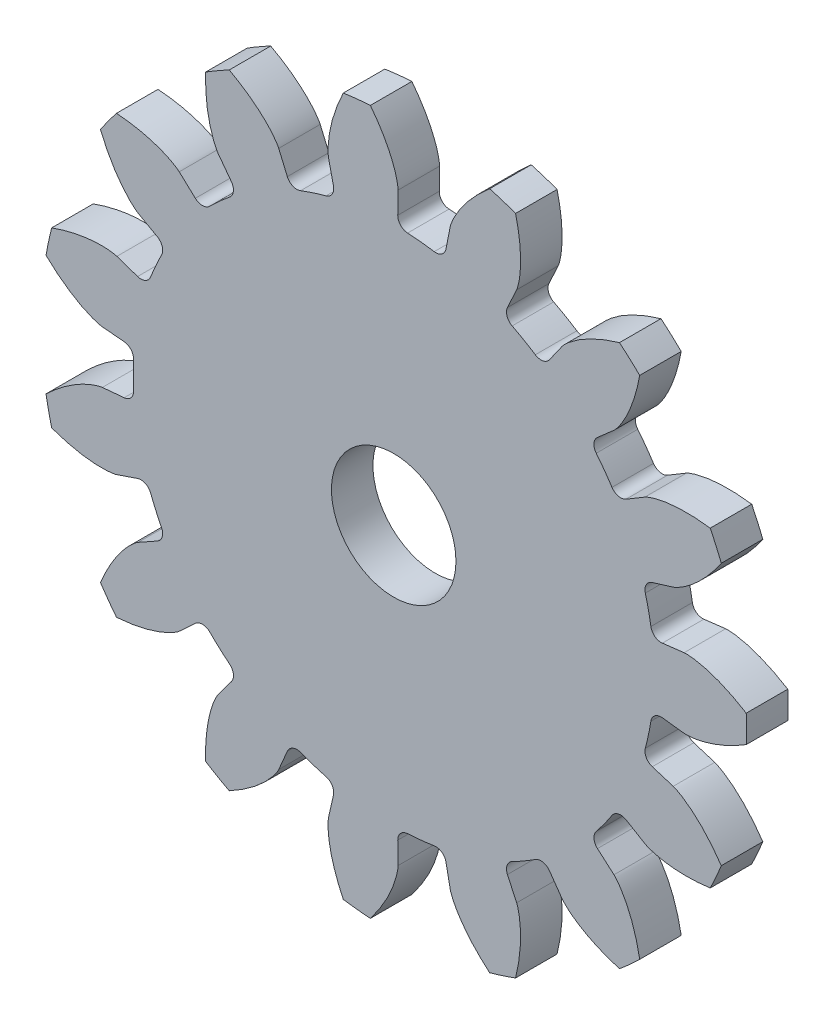
from build123d import *

# Parameters (mm, degrees)
MODEL_R             = 3
BOSS_EXTRUDE1_DEPTH = 2


with BuildPart() as part:
    # Model → Boss-Extrude1 (new body)
    with BuildSketch(Plane.XY):
        with BuildLine():
            Line((-40.339106085, -19.555024555), (-39.339331805, -19.214472473))
            ThreePointArc((-39.339331805, -19.214472473), (-38.966265776, -19.234865748), (-38.711490626, -19.508149062))
            ThreePointArc((-38.711490626, -19.508149062), (-38.464264657, -20.104219481), (-38.186724472, -20.686793142))
            ThreePointArc((-38.186724472, -20.686793142), (-38.154113242, -21.058990206), (-38.388587983, -21.349878059))
            Line((-38.388587983, -21.349878059), (-39.310647071, -21.864981321))
            add(Edge.make_bspline(
                [(-39.310647071, -21.864981321), (-39.340723268, -21.881783223), (-39.376884287, -21.904832267), (-39.438745525, -21.950927578), (-39.504377298, -22.0069371), (-39.59634197, -22.086096103), (-39.667144808, -22.150606071), (-39.754048787, -22.237149589), (-39.826725678, -22.313906045), (-39.910034786, -22.405602055), (-40.003213538, -22.513153948), (-40.115686048, -22.652832294), (-40.224830054, -22.796751807), (-40.350747834, -22.975594797), (-40.486447278, -23.183680723), (-40.611291744, -23.390511269), (-40.730532886, -23.60322251), (-40.848250358, -23.83023226), (-40.951941167, -24.045461793), (-41.027096663, -24.21237966), (-41.080501151, -24.337066072), (-41.11402213, -24.417925053), (-41.128760247, -24.454000946)],
                knots=[0, 0, 0, 0, 0, 0, 0.057142857, 0.071428571, 0.128571429, 0.142857143, 0.2, 0.214285714, 0.271428571, 0.3, 0.342857143, 0.428571429, 0.5, 0.557142857, 0.642857143, 0.728571429, 0.8, 0.871428571, 0.942857143, 1, 1, 1, 1, 1, 1], degree=5))
            ThreePointArc((-41.128760247, -24.454000946), (-40.753288904, -24.992349289), (-40.35731623, -25.515802543))
            add(Edge.make_bspline(
                [(-40.35731623, -25.515802543), (-40.23100647, -25.50647921), (-40.066969128, -25.491592609), (-39.856578115, -25.467755181), (-39.601803409, -25.431080946), (-39.314571295, -25.378285315), (-39.104311827, -25.333708174), (-38.897246454, -25.283323131), (-38.702368557, -25.229655203), (-38.536771202, -25.178838377), (-38.37394361, -25.123669236), (-38.238964411, -25.073962776), (-38.114338735, -25.024550366), (-38.008194992, -24.979035906), (-37.895687627, -24.927548142), (-37.808468394, -24.885560414), (-37.715184977, -24.837247194), (-37.639455715, -24.794265366), (-37.557620003, -24.745189836), (-37.48393768, -24.699993951), (-37.419233039, -24.657622402), (-37.378164849, -24.626698137), (-37.345821184, -24.598431267), (-37.333184376, -24.586725223)],
                knots=[-1, -1, -1, -1, -1, -1, -0.814285714, -0.757142857, -0.685714286, -0.614285714, -0.557142857, -0.485714286, -0.428571429, -0.371428571, -0.342857143, -0.285714286, -0.257142857, -0.214285714, -0.185714286, -0.142857143, -0.128571429, -0.085714286, -0.071428571, -0.028571429, 0, 0, 0, 0, 0, 0], degree=5))
            Line((-37.333184376, -24.586725223), (-36.558360135, -23.86897058))
            ThreePointArc((-36.558360135, -23.86897058), (-36.209252667, -23.73586114), (-35.865349647, -23.881891481))
            ThreePointArc((-35.865349647, -23.881891481), (-35.397053805, -24.325873044), (-34.906554175, -24.745194802))
            ThreePointArc((-34.906554175, -24.745194802), (-34.725376149, -25.071949557), (-34.821264735, -25.433058303))
            Line((-34.821264735, -25.433058303), (-35.454096255, -26.278663766))
            add(Edge.make_bspline(
                [(-35.454096255, -26.278663766), (-35.474738279, -26.306246159), (-35.498398123, -26.34201052), (-35.536162524, -26.409281914), (-35.573339007, -26.487144006), (-35.625156049, -26.596864755), (-35.663599092, -26.684595653), (-35.707789406, -26.799004123), (-35.742963387, -26.898684989), (-35.781773917, -27.016338329), (-35.823151646, -27.152491085), (-35.869088096, -27.325840295), (-35.910258767, -27.501710179), (-35.952548386, -27.716306755), (-35.991879825, -27.961596644), (-36.021805358, -28.201324569), (-36.044220106, -28.444145699), (-36.059427184, -28.699409434), (-36.066611713, -28.938206248), (-36.067378063, -29.121261802), (-36.065450958, -29.256890069), (-36.063185586, -29.344392634), (-36.061976137, -29.383344134)],
                knots=[0, 0, 0, 0, 0, 0, 0.057142857, 0.071428571, 0.128571429, 0.142857143, 0.2, 0.214285714, 0.271428571, 0.3, 0.342857143, 0.428571429, 0.5, 0.557142857, 0.642857143, 0.728571429, 0.8, 0.871428571, 0.942857143, 1, 1, 1, 1, 1, 1], degree=5))
            ThreePointArc((-36.061976137, -29.383344134), (-35.5, -29.722431864), (-34.925353343, -30.039573611))
            add(Edge.make_bspline(
                [(-34.925353343, -30.039573611), (-34.813755776, -29.979681514), (-34.669955134, -29.89936193), (-34.487448935, -29.792011622), (-34.269617415, -29.654881832), (-34.02869174, -29.489822797), (-33.854741314, -29.363579322), (-33.686071126, -29.233329221), (-33.529870022, -29.105037147), (-33.399258375, -28.991259154), (-33.272947279, -28.874631688), (-33.169855084, -28.774321591), (-33.076101702, -28.678491279), (-32.997646967, -28.593739201), (-32.915808334, -28.50094192), (-32.853207547, -28.427108964), (-32.787639663, -28.345030857), (-32.735939824, -28.274963138), (-32.681139998, -28.196844828), (-32.632210668, -28.125587031), (-32.590334099, -28.060560947), (-32.565394473, -28.015606287), (-32.547344235, -27.976627863), (-32.540561215, -27.960794006)],
                knots=[-1, -1, -1, -1, -1, -1, -0.814285714, -0.757142857, -0.685714286, -0.614285714, -0.557142857, -0.485714286, -0.428571429, -0.371428571, -0.342857143, -0.285714286, -0.257142857, -0.214285714, -0.185714286, -0.142857143, -0.128571429, -0.085714286, -0.071428571, -0.028571429, 0, 0, 0, 0, 0, 0], degree=5))
            Line((-32.540561215, -27.960794006), (-32.124661162, -26.989943102))
            ThreePointArc((-32.124661162, -26.989943102), (-31.859876108, -26.726346778), (-31.486309176, -26.719874173))
            ThreePointArc((-31.486309176, -26.719874173), (-30.877916066, -26.934998434), (-30.259268832, -27.118563748))
            ThreePointArc((-30.259268832, -27.118563748), (-29.960851338, -27.343377329), (-29.901573761, -27.712267985))
            Line((-29.901573761, -27.712267985), (-30.135755394, -28.742162783))
            add(Edge.make_bspline(
                [(-30.135755394, -28.742162783), (-30.14339405, -28.77575642), (-30.150461718, -28.818052116), (-30.157599474, -28.894867757), (-30.159892515, -28.981119355), (-30.162602289, -29.102430137), (-30.162038386, -29.198212494), (-30.15587413, -29.320703653), (-30.147463299, -29.426073202), (-30.135064558, -29.549340541), (-30.11748668, -29.690552112), (-30.088944238, -29.867598533), (-30.055022792, -30.045009287), (-30.00637199, -30.258253752), (-29.942534662, -30.498334753), (-29.872366865, -30.729508921), (-29.794079505, -30.960453961), (-29.704146747, -31.199834261), (-29.613582727, -31.420908218), (-29.539827421, -31.58844949), (-29.482901937, -31.711568253), (-29.445241917, -31.790584414), (-29.428294028, -31.825676453)],
                knots=[0, 0, 0, 0, 0, 0, 0.057142857, 0.071428571, 0.128571429, 0.142857143, 0.2, 0.214285714, 0.271428571, 0.3, 0.342857143, 0.428571429, 0.5, 0.557142857, 0.642857143, 0.728571429, 0.8, 0.871428571, 0.942857143, 1, 1, 1, 1, 1, 1], degree=5))
            ThreePointArc((-29.428294028, -31.825676453), (-28.776983876, -31.906872221), (-28.123024863, -31.962865771))
            add(Edge.make_bspline(
                [(-28.123024863, -31.962865771), (-28.045435723, -31.862760798), (-27.946736218, -31.730896216), (-27.823671813, -31.558594872), (-27.680448527, -31.344720514), (-27.527487529, -31.095938282), (-27.419923755, -30.909857117), (-27.31881336, -30.722263382), (-27.228297638, -30.541530028), (-27.155255641, -30.384464116), (-27.087301377, -30.226544273), (-27.033921762, -30.092975066), (-26.987251485, -29.967296784), (-26.950051294, -29.857961493), (-26.913032037, -29.739900188), (-26.885873942, -29.646988392), (-26.859358872, -29.545337449), (-26.840627828, -29.460299184), (-26.822339275, -29.366645459), (-26.806623265, -29.281646872), (-26.794815606, -29.205209852), (-26.790316832, -29.153997867), (-26.789681073, -29.111047612), (-26.789924685, -29.093823761)],
                knots=[-1, -1, -1, -1, -1, -1, -0.814285714, -0.757142857, -0.685714286, -0.614285714, -0.557142857, -0.485714286, -0.428571429, -0.371428571, -0.342857143, -0.285714286, -0.257142857, -0.214285714, -0.185714286, -0.142857143, -0.128571429, -0.085714286, -0.071428571, -0.028571429, 0, 0, 0, 0, 0, 0], degree=5))
            Line((-26.789924685, -29.093823761), (-26.804861719, -28.037745536))
            ThreePointArc((-26.804861719, -28.037745536), (-26.670182819, -27.689240527), (-26.331545091, -27.531384148))
            ThreePointArc((-26.331545091, -27.531384148), (-25.688251409, -27.480454169), (-25.048426299, -27.396522929))
            ThreePointArc((-25.048426299, -27.396522929), (-24.684368431, -27.480523025), (-24.480174323, -27.793411045))
            Line((-24.480174323, -27.793411045), (-24.275213937, -28.829517011))
            add(Edge.make_bspline(
                [(-24.275213937, -28.829517011), (-24.268528434, -28.863313247), (-24.25778186, -28.904826967), (-24.233058788, -28.977904734), (-24.200071901, -29.057632154), (-24.153205862, -29.169557232), (-24.113732516, -29.256829409), (-24.058279546, -29.366223422), (-24.007738213, -29.459062302), (-23.946274055, -29.566629597), (-23.872779944, -29.688483219), (-23.77469386, -29.838613916), (-23.671545622, -29.986889609), (-23.540366566, -30.161910058), (-23.384398524, -30.355269985), (-23.226270047, -30.537918282), (-23.060817174, -30.717054736), (-22.881294772, -30.899160575), (-22.708641544, -31.064285978), (-22.573117544, -31.18734356), (-22.471036614, -31.276664467), (-22.404493706, -31.333531611), (-22.374737821, -31.358696457)],
                knots=[0, 0, 0, 0, 0, 0, 0.057142857, 0.071428571, 0.128571429, 0.142857143, 0.2, 0.214285714, 0.271428571, 0.3, 0.342857143, 0.428571429, 0.5, 0.557142857, 0.642857143, 0.728571429, 0.8, 0.871428571, 0.942857143, 1, 1, 1, 1, 1, 1], degree=5))
            ThreePointArc((-22.374737821, -31.358696457), (-21.746711096, -31.167960777), (-21.126515182, -30.953124336))
            add(Edge.make_bspline(
                [(-21.126515182, -30.953124336), (-21.096350336, -30.830115547), (-21.059818008, -30.669506552), (-21.017474351, -30.462046638), (-20.973623907, -30.208408531), (-20.935075932, -29.918919811), (-20.912497563, -29.705176079), (-20.896429867, -29.492675372), (-20.887250518, -29.290751177), (-20.884407795, -29.11755547), (-20.886560273, -28.945649025), (-20.892123059, -28.801916038), (-20.900605602, -28.668120702), (-20.911092206, -28.553107262), (-20.925293291, -28.430195806), (-20.938273768, -28.334270464), (-20.95539621, -28.230623056), (-20.972872728, -28.145318133), (-20.994257705, -28.052322574), (-21.014472456, -27.968280223), (-21.03477536, -27.893648924), (-21.051495316, -27.845034631), (-21.068383964, -27.805539034), (-21.075612085, -27.789903349)],
                knots=[-1, -1, -1, -1, -1, -1, -0.814285714, -0.757142857, -0.685714286, -0.614285714, -0.557142857, -0.485714286, -0.428571429, -0.371428571, -0.342857143, -0.285714286, -0.257142857, -0.214285714, -0.185714286, -0.142857143, -0.128571429, -0.085714286, -0.071428571, -0.028571429, 0, 0, 0, 0, 0, 0], degree=5))
            Line((-21.075612085, -27.789903349), (-21.518803457, -26.831203323))
            ThreePointArc((-21.518803457, -26.831203323), (-21.537517917, -26.458049312), (-21.292362932, -26.176103961))
            ThreePointArc((-21.292362932, -26.176103961), (-20.7254, -25.867925997), (-20.175028588, -25.531010677))
            ThreePointArc((-20.175028588, -25.531010677), (-19.80827926, -25.459672907), (-19.494475636, -25.662457111))
            Line((-19.494475636, -25.662457111), (-18.885812745, -26.525622111))
            add(Edge.make_bspline(
                [(-18.885812745, -26.525622111), (-18.865959066, -26.55377727), (-18.839256432, -26.587330914), (-18.786947376, -26.644034997), (-18.724384291, -26.703452644), (-18.636046004, -26.786639155), (-18.564488516, -26.850311), (-18.469335153, -26.927692648), (-18.385402374, -26.991948173), (-18.285500511, -27.065216062), (-18.168797967, -27.146642137), (-18.018128214, -27.243898148), (-17.863588453, -27.337400566), (-17.672563191, -27.443934373), (-17.451432727, -27.557139538), (-17.23268542, -27.659680415), (-17.00867534, -27.756033962), (-16.770604348, -27.849377585), (-16.545715223, -27.930002752), (-16.371855861, -27.987298871), (-16.242270205, -28.027377525), (-16.158350282, -28.052262807), (-16.120931464, -28.063149229)],
                knots=[0, 0, 0, 0, 0, 0, 0.057142857, 0.071428571, 0.128571429, 0.142857143, 0.2, 0.214285714, 0.271428571, 0.3, 0.342857143, 0.428571429, 0.5, 0.557142857, 0.642857143, 0.728571429, 0.8, 0.871428571, 0.942857143, 1, 1, 1, 1, 1, 1], degree=5))
            ThreePointArc((-16.120931464, -28.063149229), (-15.624779692, -27.633462033), (-15.145584385, -27.184942775))
            add(Edge.make_bspline(
                [(-15.145584385, -27.184942775), (-15.168059609, -27.060299506), (-15.200011231, -26.898716851), (-15.245709923, -26.691970072), (-15.308814462, -26.44242455), (-15.391344805, -26.16228457), (-15.457655846, -25.957836505), (-15.5294091, -25.757172128), (-15.603153317, -25.56897162), (-15.6710014, -25.409593229), (-15.742888437, -25.253424369), (-15.806431767, -25.12438034), (-15.868600422, -25.00560238), (-15.924960591, -24.90479766), (-15.987926521, -24.798288559), (-16.038801129, -24.715936034), (-16.096600456, -24.628213741), (-16.147262689, -24.557392156), (-16.204623539, -24.481134539), (-16.257273736, -24.412580111), (-16.306176646, -24.352658961), (-16.3412243, -24.315048214), (-16.372717154, -24.285836423), (-16.385679978, -24.274492456)],
                knots=[-1, -1, -1, -1, -1, -1, -0.814285714, -0.757142857, -0.685714286, -0.614285714, -0.557142857, -0.485714286, -0.428571429, -0.371428571, -0.342857143, -0.285714286, -0.257142857, -0.214285714, -0.185714286, -0.142857143, -0.128571429, -0.085714286, -0.071428571, -0.028571429, 0, 0, 0, 0, 0, 0], degree=5))
            Line((-16.385679978, -24.274492456), (-17.180493872, -23.578938572))
            ThreePointArc((-17.180493872, -23.578938572), (-17.349365793, -23.245657277), (-17.240083075, -22.888373867))
            ThreePointArc((-17.240083075, -22.888373867), (-16.847483934, -22.376234688), (-16.481730437, -21.844591007))
            ThreePointArc((-16.481730437, -21.844591007), (-16.175703939, -21.630250321), (-15.806550298, -21.687867477))
            Line((-15.806550298, -21.687867477), (-14.899428244, -22.22884244))
            add(Edge.make_bspline(
                [(-14.899428244, -22.22884244), (-14.869839271, -22.246488239), (-14.831797704, -22.266280079), (-14.760947375, -22.296805827), (-14.67962582, -22.325639849), (-14.565089776, -22.36570409), (-14.473821086, -22.394766162), (-14.355420211, -22.426755456), (-14.252608725, -22.451317262), (-14.131543097, -22.477617061), (-13.99181105, -22.50453628), (-13.814609798, -22.532101158), (-13.635399841, -22.554662884), (-13.417558378, -22.574289386), (-13.169500959, -22.587765588), (-12.927958218, -22.592468794), (-12.684124308, -22.589379032), (-12.428669363, -22.577820478), (-12.190429715, -22.560004586), (-12.008296853, -22.541632222), (-11.873613009, -22.525538659), (-11.786826588, -22.514139188), (-11.74821489, -22.508864825)],
                knots=[0, 0, 0, 0, 0, 0, 0.057142857, 0.071428571, 0.128571429, 0.142857143, 0.2, 0.214285714, 0.271428571, 0.3, 0.342857143, 0.428571429, 0.5, 0.557142857, 0.642857143, 0.728571429, 0.8, 0.871428571, 0.942857143, 1, 1, 1, 1, 1, 1], degree=5))
            ThreePointArc((-11.74821489, -22.508864825), (-11.46972722, -21.914522932), (-11.214389741, -21.30987391))
            add(Edge.make_bspline(
                [(-11.214389741, -21.30987391), (-11.285618865, -21.205148116), (-11.380529711, -21.070530911), (-11.506369035, -20.900245663), (-11.665517207, -20.697941413), (-11.854855622, -20.475588921), (-11.998590293, -20.315787451), (-12.145757706, -20.161656098), (-12.289674444, -20.019720853), (-12.416481784, -19.90171775), (-12.545673457, -19.788289489), (-12.656210114, -19.696247304), (-12.761315354, -19.613024508), (-12.853803904, -19.54385856), (-12.954647298, -19.472168206), (-13.034619354, -19.417627998), (-13.123101538, -19.360998799), (-13.198189524, -19.316906249), (-13.281608035, -19.270572208), (-13.357589982, -19.229359387), (-13.42663714, -19.194509298), (-13.473952434, -19.174405336), (-13.514604094, -19.160528334), (-13.53106023, -19.155437561)],
                knots=[-1, -1, -1, -1, -1, -1, -0.814285714, -0.757142857, -0.685714286, -0.614285714, -0.557142857, -0.485714286, -0.428571429, -0.371428571, -0.342857143, -0.285714286, -0.257142857, -0.214285714, -0.185714286, -0.142857143, -0.128571429, -0.085714286, -0.071428571, -0.028571429, 0, 0, 0, 0, 0, 0], degree=5))
            Line((-13.53106023, -19.155437561), (-14.540066105, -18.843297405))
            ThreePointArc((-14.540066105, -18.843297405), (-14.829895996, -18.607516189), (-14.875381521, -18.236672268))
            ThreePointArc((-14.875381521, -18.236672268), (-14.725030129, -17.60912539), (-14.60713665, -16.974679371))
            ThreePointArc((-14.60713665, -16.974679371), (-14.414747743, -16.65439722), (-14.054074103, -16.556884799))
            Line((-14.054074103, -16.556884799), (-13.00534253, -16.68213024))
            add(Edge.make_bspline(
                [(-13.00534253, -16.68213024), (-12.971134465, -16.68621556), (-12.928331698, -16.688823406), (-12.851190762, -16.687892639), (-12.765171971, -16.681157372), (-12.644242493, -16.671171872), (-12.549043786, -16.660599075), (-12.427867987, -16.641664775), (-12.323954834, -16.622285903), (-12.202658788, -16.597070138), (-12.064058178, -16.564827924), (-11.890965133, -16.517935451), (-11.718072011, -16.465655357), (-11.511081115, -16.394980953), (-11.27898812, -16.306398034), (-11.05641488, -16.212450343), (-10.834918239, -16.110451519), (-10.606249822, -15.995989368), (-10.39585345, -15.882812946), (-10.236939515, -15.791948848), (-10.120445542, -15.722465792), (-10.045798784, -15.676752639), (-10.01267052, -15.656229476)],
                knots=[0, 0, 0, 0, 0, 0, 0.057142857, 0.071428571, 0.128571429, 0.142857143, 0.2, 0.214285714, 0.271428571, 0.3, 0.342857143, 0.428571429, 0.5, 0.557142857, 0.642857143, 0.728571429, 0.8, 0.871428571, 0.942857143, 1, 1, 1, 1, 1, 1], degree=5))
            ThreePointArc((-10.01267052, -15.656229476), (-10, -15), (-10.01267052, -14.343770524))
            add(Edge.make_bspline(
                [(-10.01267052, -14.343770524), (-10.12033738, -14.277070244), (-10.261796502, -14.192695027), (-10.446017695, -14.088315176), (-10.673691337, -13.968232441), (-10.937099491, -13.842114204), (-11.133404761, -13.754590453), (-11.330539752, -13.673642836), (-11.519744498, -13.602514749), (-11.683584954, -13.546290742), (-11.847742851, -13.495215857), (-11.986160041, -13.456090445), (-12.116028216, -13.42281279), (-12.228653037, -13.397245036), (-12.349937155, -13.372769341), (-12.445178764, -13.355471948), (-12.549044432, -13.339727547), (-12.635574776, -13.329988033), (-12.730627131, -13.321589146), (-12.816802857, -13.314844002), (-12.894055383, -13.311090872), (-12.945457073, -13.311969852), (-12.988238498, -13.3158271), (-13.00534253, -13.31786976)],
                knots=[-1, -1, -1, -1, -1, -1, -0.814285714, -0.757142857, -0.685714286, -0.614285714, -0.557142857, -0.485714286, -0.428571429, -0.371428571, -0.342857143, -0.285714286, -0.257142857, -0.214285714, -0.185714286, -0.142857143, -0.128571429, -0.085714286, -0.071428571, -0.028571429, 0, 0, 0, 0, 0, 0], degree=5))
            Line((-13.00534253, -13.31786976), (-14.054074103, -13.443115201))
            ThreePointArc((-14.054074103, -13.443115201), (-14.414747743, -13.34560278), (-14.60713665, -13.025320629))
            ThreePointArc((-14.60713665, -13.025320629), (-14.725030129, -12.39087461), (-14.875381521, -11.763327732))
            ThreePointArc((-14.875381521, -11.763327732), (-14.829895996, -11.392483811), (-14.540066105, -11.156702595))
            Line((-14.540066105, -11.156702595), (-13.53106023, -10.844562439))
            add(Edge.make_bspline(
                [(-13.53106023, -10.844562439), (-13.498147959, -10.834380892), (-13.457984978, -10.819353824), (-13.387891803, -10.78712748), (-13.312049207, -10.745987514), (-13.205636102, -10.687678856), (-13.122968099, -10.639299323), (-13.019969772, -10.572715341), (-12.93292248, -10.512746574), (-12.832369204, -10.440375279), (-12.718865336, -10.354546604), (-12.579809858, -10.241304915), (-12.443128362, -10.123222704), (-12.282778638, -9.974467641), (-12.106781057, -9.799142392), (-11.941662253, -9.622788214), (-11.780801662, -9.439516851), (-11.618458619, -9.241942648), (-11.472284967, -9.052974928), (-11.364067622, -8.905330323), (-11.285906387, -8.794472026), (-11.236306395, -8.722349411), (-11.214389741, -8.69012609)],
                knots=[0, 0, 0, 0, 0, 0, 0.057142857, 0.071428571, 0.128571429, 0.142857143, 0.2, 0.214285714, 0.271428571, 0.3, 0.342857143, 0.428571429, 0.5, 0.557142857, 0.642857143, 0.728571429, 0.8, 0.871428571, 0.942857143, 1, 1, 1, 1, 1, 1], degree=5))
            ThreePointArc((-11.214389741, -8.69012609), (-11.46972722, -8.085477068), (-11.74821489, -7.491135175))
            add(Edge.make_bspline(
                [(-11.74821489, -7.491135175), (-11.873702909, -7.473993495), (-12.03725074, -7.454449507), (-12.248000284, -7.434023278), (-12.504832554, -7.416925453), (-12.796764786, -7.408848459), (-13.011697689, -7.408736081), (-13.224713827, -7.414968778), (-13.426491363, -7.42694654), (-13.599035431, -7.442223271), (-13.769775159, -7.462333073), (-13.912139293, -7.482889574), (-14.044315016, -7.50531107), (-14.157602252, -7.527762405), (-14.278355969, -7.554733441), (-14.372398993, -7.577669738), (-14.473688826, -7.605532486), (-14.556699647, -7.631830059), (-14.646950428, -7.662818569), (-14.728419369, -7.691707399), (-14.800519599, -7.719700176), (-14.847119866, -7.741410116), (-14.884633758, -7.76233466), (-14.899428244, -7.77115756)],
                knots=[-1, -1, -1, -1, -1, -1, -0.814285714, -0.757142857, -0.685714286, -0.614285714, -0.557142857, -0.485714286, -0.428571429, -0.371428571, -0.342857143, -0.285714286, -0.257142857, -0.214285714, -0.185714286, -0.142857143, -0.128571429, -0.085714286, -0.071428571, -0.028571429, 0, 0, 0, 0, 0, 0], degree=5))
            Line((-14.899428244, -7.77115756), (-15.806550298, -8.312132523))
            ThreePointArc((-15.806550298, -8.312132523), (-16.175703939, -8.369749679), (-16.481730437, -8.155408993))
            ThreePointArc((-16.481730437, -8.155408993), (-16.847483934, -7.623765312), (-17.240083075, -7.111626133))
            ThreePointArc((-17.240083075, -7.111626133), (-17.349365793, -6.754342723), (-17.180493872, -6.421061428))
            Line((-17.180493872, -6.421061428), (-16.385679978, -5.725507544))
            add(Edge.make_bspline(
                [(-16.385679978, -5.725507544), (-16.35975433, -5.702819611), (-16.329175681, -5.672755945), (-16.278250014, -5.614806253), (-16.225697487, -5.54637506), (-16.152200546, -5.449825341), (-16.096357296, -5.372004333), (-16.029345787, -5.269283645), (-15.974215625, -5.179094127), (-15.911791694, -5.072080957), (-15.843010417, -4.947506379), (-15.762036462, -4.78749599), (-15.685200064, -4.624029149), (-15.599217437, -4.422914529), (-15.509746849, -4.191162279), (-15.430633023, -3.962894852), (-15.358222739, -3.730040235), (-15.290275658, -3.483516355), (-15.233599478, -3.251431571), (-15.194790485, -3.072535554), (-15.168476776, -2.939470422), (-15.152499838, -2.853409), (-15.145584385, -2.815057225)],
                knots=[0, 0, 0, 0, 0, 0, 0.057142857, 0.071428571, 0.128571429, 0.142857143, 0.2, 0.214285714, 0.271428571, 0.3, 0.342857143, 0.428571429, 0.5, 0.557142857, 0.642857143, 0.728571429, 0.8, 0.871428571, 0.942857143, 1, 1, 1, 1, 1, 1], degree=5))
            ThreePointArc((-15.145584385, -2.815057225), (-15.624779692, -2.366537967), (-16.120931464, -1.936850771))
            add(Edge.make_bspline(
                [(-16.120931464, -1.936850771), (-16.242542623, -1.972231642), (-16.399900257, -2.020898216), (-16.600737642, -2.08795749), (-16.842319907, -2.176800945), (-17.112298481, -2.28816178), (-17.308695167, -2.375480205), (-17.500760026, -2.467815525), (-17.680221183, -2.560828074), (-17.831634426, -2.644964056), (-17.979433536, -2.732781379), (-18.101128561, -2.809465387), (-18.212757449, -2.883709152), (-18.307118708, -2.950297538), (-18.406462609, -3.024051766), (-18.483046153, -3.08325586), (-18.56424622, -3.149908034), (-18.629384192, -3.207695604), (-18.69922822, -3.272713317), (-18.761903655, -3.33224098), (-18.816384805, -3.38713946), (-18.850126039, -3.425926513), (-18.875885906, -3.46030031), (-18.885812745, -3.474377889)],
                knots=[-1, -1, -1, -1, -1, -1, -0.814285714, -0.757142857, -0.685714286, -0.614285714, -0.557142857, -0.485714286, -0.428571429, -0.371428571, -0.342857143, -0.285714286, -0.257142857, -0.214285714, -0.185714286, -0.142857143, -0.128571429, -0.085714286, -0.071428571, -0.028571429, 0, 0, 0, 0, 0, 0], degree=5))
            Line((-18.885812745, -3.474377889), (-19.494475636, -4.337542889))
            ThreePointArc((-19.494475636, -4.337542889), (-19.80827926, -4.540327093), (-20.175028588, -4.468989323))
            ThreePointArc((-20.175028588, -4.468989323), (-20.7254, -4.132074003), (-21.292362932, -3.823896039))
            ThreePointArc((-21.292362932, -3.823896039), (-21.537517917, -3.541950688), (-21.518803457, -3.168796677))
            Line((-21.518803457, -3.168796677), (-21.075612085, -2.210096651))
            add(Edge.make_bspline(
                [(-21.075612085, -2.210096651), (-21.061155842, -2.178825281), (-21.04544885, -2.138923299), (-21.022496202, -2.065270286), (-21.002320553, -1.981380243), (-20.974448064, -1.863283786), (-20.955085373, -1.769477261), (-20.935647582, -1.648381207), (-20.921967054, -1.543565526), (-20.908466133, -1.420414031), (-20.896300355, -1.278633625), (-20.887409055, -1.099521786), (-20.883703467, -0.918935217), (-20.886955114, -0.700235585), (-20.899481797, -0.452128403), (-20.920052447, -0.21141724), (-20.948612867, 0.030757954), (-20.986810415, 0.283605293), (-21.029431534, 0.518677571), (-21.06674132, 0.697892255), (-21.096825016, 0.830156052), (-21.117233691, 0.915275478), (-21.126515182, 0.953124336)],
                knots=[0, 0, 0, 0, 0, 0, 0.057142857, 0.071428571, 0.128571429, 0.142857143, 0.2, 0.214285714, 0.271428571, 0.3, 0.342857143, 0.428571429, 0.5, 0.557142857, 0.642857143, 0.728571429, 0.8, 0.871428571, 0.942857143, 1, 1, 1, 1, 1, 1], degree=5))
            ThreePointArc((-21.126515182, 0.953124336), (-21.746711096, 1.167960777), (-22.374737821, 1.358696457))
            add(Edge.make_bspline(
                [(-22.374737821, 1.358696457), (-22.471444446, 1.276910708), (-22.595403319, 1.168448464), (-22.751601935, 1.025498846), (-22.936162428, 0.846075951), (-23.137505596, 0.634532588), (-23.281407293, 0.474881509), (-23.419311114, 0.31240918), (-23.545425427, 0.154444561), (-23.649527121, 0.015997201), (-23.748829803, -0.124343229), (-23.828813545, -0.243895382), (-23.900593948, -0.357123996), (-23.959713311, -0.456335694), (-24.020469934, -0.56412034), (-24.066352008, -0.649355305), (-24.113422079, -0.743272137), (-24.149424255, -0.82255771), (-24.186784864, -0.910362472), (-24.219829641, -0.990236094), (-24.247271424, -1.062547831), (-24.262319459, -1.111705363), (-24.271871186, -1.153584871), (-24.275213937, -1.170482989)],
                knots=[-1, -1, -1, -1, -1, -1, -0.814285714, -0.757142857, -0.685714286, -0.614285714, -0.557142857, -0.485714286, -0.428571429, -0.371428571, -0.342857143, -0.285714286, -0.257142857, -0.214285714, -0.185714286, -0.142857143, -0.128571429, -0.085714286, -0.071428571, -0.028571429, 0, 0, 0, 0, 0, 0], degree=5))
            Line((-24.275213937, -1.170482989), (-24.480174323, -2.206588955))
            ThreePointArc((-24.480174323, -2.206588955), (-24.684368431, -2.519476975), (-25.048426299, -2.603477071))
            ThreePointArc((-25.048426299, -2.603477071), (-25.688251409, -2.519545831), (-26.331545091, -2.468615852))
            ThreePointArc((-26.331545091, -2.468615852), (-26.670182819, -2.310759473), (-26.804861719, -1.962254464))
            Line((-26.804861719, -1.962254464), (-26.789924685, -0.906176239))
            add(Edge.make_bspline(
                [(-26.789924685, -0.906176239), (-26.789437461, -0.871728537), (-26.791318009, -0.828887654), (-26.8003071, -0.752266595), (-26.815996882, -0.667423051), (-26.838568253, -0.548199807), (-26.859034106, -0.454627767), (-26.890531002, -0.336094955), (-26.920665597, -0.234776693), (-26.958422117, -0.116780884), (-27.004975413, 0.017690228), (-27.069704154, 0.184933453), (-27.139770105, 0.351414691), (-27.231693787, 0.549884183), (-27.344051764, 0.771446311), (-27.460750038, 0.982980063), (-27.585342805, 1.192601542), (-27.723080279, 1.408052738), (-27.857629119, 1.605466379), (-27.964606483, 1.754011882), (-28.04588584, 1.862604731), (-28.099151281, 1.932064241), (-28.123024863, 1.962865771)],
                knots=[0, 0, 0, 0, 0, 0, 0.057142857, 0.071428571, 0.128571429, 0.142857143, 0.2, 0.214285714, 0.271428571, 0.3, 0.342857143, 0.428571429, 0.5, 0.557142857, 0.642857143, 0.728571429, 0.8, 0.871428571, 0.942857143, 1, 1, 1, 1, 1, 1], degree=5))
            ThreePointArc((-28.123024863, 1.962865771), (-28.776983876, 1.906872221), (-29.428294028, 1.825676453))
            add(Edge.make_bspline(
                [(-29.428294028, 1.825676453), (-29.483374665, 1.711627326), (-29.552501162, 1.56212352), (-29.63705285, 1.368000844), (-29.732679384, 1.129022359), (-29.830573083, 0.853874236), (-29.89709788, 0.649495625), (-29.95699584, 0.44497923), (-30.007956999, 0.249376056), (-30.046747014, 0.080556127), (-30.080382933, -0.088041275), (-30.104825476, -0.22978992), (-30.124345911, -0.362425126), (-30.138001103, -0.477105534), (-30.149665075, -0.600283652), (-30.156912252, -0.696811588), (-30.161713485, -0.801754007), (-30.162354761, -0.888828385), (-30.160771961, -0.984237955), (-30.158472338, -1.070646662), (-30.154129821, -1.147868299), (-30.147882716, -1.198896528), (-30.139574722, -1.241040398), (-30.135755394, -1.257837217)],
                knots=[-1, -1, -1, -1, -1, -1, -0.814285714, -0.757142857, -0.685714286, -0.614285714, -0.557142857, -0.485714286, -0.428571429, -0.371428571, -0.342857143, -0.285714286, -0.257142857, -0.214285714, -0.185714286, -0.142857143, -0.128571429, -0.085714286, -0.071428571, -0.028571429, 0, 0, 0, 0, 0, 0], degree=5))
            Line((-30.135755394, -1.257837217), (-29.901573761, -2.287732015))
            ThreePointArc((-29.901573761, -2.287732015), (-29.960851338, -2.656622671), (-30.259268832, -2.881436252))
            ThreePointArc((-30.259268832, -2.881436252), (-30.877916066, -3.065001566), (-31.486309176, -3.280125827))
            ThreePointArc((-31.486309176, -3.280125827), (-31.859876108, -3.273653222), (-32.124661162, -3.010056898))
            Line((-32.124661162, -3.010056898), (-32.540561215, -2.039205994))
            add(Edge.make_bspline(
                [(-32.540561215, -2.039205994), (-32.554127256, -2.007538281), (-32.573270179, -1.969166074), (-32.612646715, -1.902825447), (-32.661489022, -1.831698622), (-32.730601458, -1.731963373), (-32.787357122, -1.654805272), (-32.864342607, -1.559331102), (-32.933081778, -1.479029108), (-33.015567295, -1.386591533), (-33.112790176, -1.28268099), (-33.239946771, -1.156224253), (-33.371669222, -1.032634464), (-33.536370499, -0.888712291), (-33.729132055, -0.732005322), (-33.921779762, -0.586225087), (-34.120861655, -0.445402781), (-34.334322995, -0.304601198), (-34.537534837, -0.178980806), (-34.695682422, -0.086789351), (-34.8141035, -0.020644139), (-34.89101563, 0.021145273), (-34.925353343, 0.039573611)],
                knots=[0, 0, 0, 0, 0, 0, 0.057142857, 0.071428571, 0.128571429, 0.142857143, 0.2, 0.214285714, 0.271428571, 0.3, 0.342857143, 0.428571429, 0.5, 0.557142857, 0.642857143, 0.728571429, 0.8, 0.871428571, 0.942857143, 1, 1, 1, 1, 1, 1], degree=5))
            ThreePointArc((-34.925353343, 0.039573611), (-35.5, -0.277568136), (-36.061976137, -0.616655866))
            add(Edge.make_bspline(
                [(-36.061976137, -0.616655866), (-36.065906844, -0.743248242), (-36.068248364, -0.907943043), (-36.06653337, -1.119673202), (-36.056691249, -1.376885727), (-36.034208769, -1.668062999), (-36.011853925, -1.881830224), (-35.983389123, -2.093027943), (-35.95038548, -2.292448104), (-35.91715667, -2.462450105), (-35.87930987, -2.630152456), (-35.843984876, -2.769587964), (-35.807870082, -2.898695931), (-35.773699997, -3.009015764), (-35.734254511, -3.126288738), (-35.701613688, -3.217419088), (-35.663315905, -3.315241596), (-35.628485399, -3.395048829), (-35.588232872, -3.481566026), (-35.550986475, -3.559568966), (-35.515610518, -3.628348182), (-35.489148454, -3.672423861), (-35.464417267, -3.707545037), (-35.454096255, -3.721336234)],
                knots=[-1, -1, -1, -1, -1, -1, -0.814285714, -0.757142857, -0.685714286, -0.614285714, -0.557142857, -0.485714286, -0.428571429, -0.371428571, -0.342857143, -0.285714286, -0.257142857, -0.214285714, -0.185714286, -0.142857143, -0.128571429, -0.085714286, -0.071428571, -0.028571429, 0, 0, 0, 0, 0, 0], degree=5))
            Line((-35.454096255, -3.721336234), (-34.821264735, -4.566941697))
            ThreePointArc((-34.821264735, -4.566941697), (-34.725376149, -4.928050443), (-34.906554175, -5.254805198))
            ThreePointArc((-34.906554175, -5.254805198), (-35.397053805, -5.674126956), (-35.865349647, -6.118108519))
            ThreePointArc((-35.865349647, -6.118108519), (-36.209252667, -6.26413886), (-36.558360135, -6.13102942))
            Line((-36.558360135, -6.13102942), (-37.333184376, -5.413274777))
            add(Edge.make_bspline(
                [(-37.333184376, -5.413274777), (-37.358457991, -5.389862688), (-37.391553304, -5.362594061), (-37.454508723, -5.318004762), (-37.528058278, -5.272893131), (-37.631761609, -5.209891007), (-37.714993516, -5.162488183), (-37.824156099, -5.106581006), (-37.91961422, -5.061180224), (-38.032566238, -5.01028418), (-38.163647985, -4.954901284), (-38.331245903, -4.891096552), (-38.501848847, -4.83176801), (-38.710849371, -4.767278607), (-38.950684281, -4.702522855), (-39.185970882, -4.647702865), (-39.425118833, -4.600029188), (-39.677394634, -4.55822309), (-39.914132306, -4.526116855), (-40.096104957, -4.506220187), (-40.231191676, -4.493959721), (-40.318451689, -4.487066175), (-40.35731623, -4.484197457)],
                knots=[0, 0, 0, 0, 0, 0, 0.057142857, 0.071428571, 0.128571429, 0.142857143, 0.2, 0.214285714, 0.271428571, 0.3, 0.342857143, 0.428571429, 0.5, 0.557142857, 0.642857143, 0.728571429, 0.8, 0.871428571, 0.942857143, 1, 1, 1, 1, 1, 1], degree=5))
            ThreePointArc((-40.35731623, -4.484197457), (-40.753288904, -5.007650711), (-41.128760247, -5.545999054))
            add(Edge.make_bspline(
                [(-41.128760247, -5.545999054), (-41.080861368, -5.663245707), (-41.016013043, -5.814654277), (-40.928327903, -6.00738185), (-40.814718919, -6.238354033), (-40.675747685, -6.495213259), (-40.568378556, -6.681406802), (-40.456472814, -6.862767841), (-40.345210999, -7.031523432), (-40.245708928, -7.173312613), (-40.142923464, -7.311122654), (-40.053938945, -7.424135359), (-39.968433499, -7.527392146), (-39.892346454, -7.614276102), (-39.808611994, -7.705366371), (-39.741727066, -7.77534187), (-39.666952302, -7.849130065), (-39.602672525, -7.907870758), (-39.530710297, -7.970535972), (-39.464957366, -8.026645729), (-39.404664795, -8.075089971), (-39.362563302, -8.104592017), (-39.325685169, -8.126617728), (-39.310647071, -8.135018679)],
                knots=[-1, -1, -1, -1, -1, -1, -0.814285714, -0.757142857, -0.685714286, -0.614285714, -0.557142857, -0.485714286, -0.428571429, -0.371428571, -0.342857143, -0.285714286, -0.257142857, -0.214285714, -0.185714286, -0.142857143, -0.128571429, -0.085714286, -0.071428571, -0.028571429, 0, 0, 0, 0, 0, 0], degree=5))
            Line((-39.310647071, -8.135018679), (-38.388587983, -8.650121941))
            ThreePointArc((-38.388587983, -8.650121941), (-38.154113242, -8.941009794), (-38.186724472, -9.313206858))
            ThreePointArc((-38.186724472, -9.313206858), (-38.464264657, -9.895780519), (-38.711490626, -10.491850938))
            ThreePointArc((-38.711490626, -10.491850938), (-38.966265776, -10.765134252), (-39.339331805, -10.785527527))
            Line((-39.339331805, -10.785527527), (-40.339106085, -10.444975445))
            add(Edge.make_bspline(
                [(-40.339106085, -10.444975445), (-40.371717236, -10.433867142), (-40.413042458, -10.422417088), (-40.488691197, -10.407289013), (-40.574230612, -10.395992786), (-40.694593592, -10.380617427), (-40.789910187, -10.371166258), (-40.912374667, -10.364492933), (-41.018046162, -10.361843571), (-41.141934251, -10.361289446), (-41.284209638, -10.364010402), (-41.463269678, -10.373890094), (-41.643254314, -10.389081242), (-41.860415997, -10.415175413), (-42.105854627, -10.453567736), (-42.343096931, -10.499186866), (-42.580960087, -10.55290503), (-42.82842957, -10.617323071), (-43.057758978, -10.684282451), (-43.232091971, -10.740120886), (-43.36048661, -10.783865112), (-43.443006456, -10.813059388), (-43.479677794, -10.826246317)],
                knots=[0, 0, 0, 0, 0, 0, 0.057142857, 0.071428571, 0.128571429, 0.142857143, 0.2, 0.214285714, 0.271428571, 0.3, 0.342857143, 0.428571429, 0.5, 0.557142857, 0.642857143, 0.728571429, 0.8, 0.871428571, 0.942857143, 1, 1, 1, 1, 1, 1], degree=5))
            ThreePointArc((-43.479677794, -10.826246317), (-43.628509212, -11.465501256), (-43.752553354, -12.110024893))
            add(Edge.make_bspline(
                [(-43.752553354, -12.110024893), (-43.661107041, -12.19765281), (-43.540281734, -12.309595232), (-43.381788008, -12.449995872), (-43.184056186, -12.614790523), (-42.952625587, -12.792918409), (-42.77880727, -12.919343716), (-42.602810107, -13.039509103), (-42.432528299, -13.14842075), (-42.283957779, -13.237480474), (-42.134006192, -13.321569596), (-42.00674838, -13.388618576), (-41.886636949, -13.448170145), (-41.781789086, -13.4965952), (-41.6682441, -13.545752428), (-41.578680079, -13.582473676), (-41.48035757, -13.61946891), (-41.39774308, -13.646986262), (-41.306514075, -13.674964109), (-41.223623889, -13.699478797), (-41.148839836, -13.719211616), (-41.098378645, -13.729038856), (-41.055730131, -13.734160656), (-41.03857517, -13.735718761)],
                knots=[-1, -1, -1, -1, -1, -1, -0.814285714, -0.757142857, -0.685714286, -0.614285714, -0.557142857, -0.485714286, -0.428571429, -0.371428571, -0.342857143, -0.285714286, -0.257142857, -0.214285714, -0.185714286, -0.142857143, -0.128571429, -0.085714286, -0.071428571, -0.028571429, 0, 0, 0, 0, 0, 0], degree=5))
            Line((-41.03857517, -13.735718761), (-39.986720907, -13.831253788))
            ThreePointArc((-39.986720907, -13.831253788), (-39.654202823, -14.001623596), (-39.532608479, -14.354906716))
            ThreePointArc((-39.532608479, -14.354906716), (-39.5492, -15), (-39.532608479, -15.645093284))
            ThreePointArc((-39.532608479, -15.645093284), (-39.654202823, -15.998376404), (-39.986720907, -16.168746212))
            Line((-39.986720907, -16.168746212), (-41.03857517, -16.264281239))
            add(Edge.make_bspline(
                [(-41.03857517, -16.264281239), (-41.072885092, -16.267397449), (-41.115294718, -16.273745787), (-41.190556422, -16.290694716), (-41.273295156, -16.315167114), (-41.389505931, -16.350077059), (-41.48042611, -16.380211739), (-41.595017265, -16.423926145), (-41.692630572, -16.464486301), (-41.806033356, -16.514369908), (-41.934901678, -16.574724238), (-42.09446273, -16.656580066), (-42.252708081, -16.743664216), (-42.440481694, -16.855830042), (-42.649085475, -16.990732059), (-42.847262133, -17.128902345), (-43.042711793, -17.274723992), (-43.242585237, -17.434227708), (-43.424853243, -17.588674819), (-43.561402819, -17.710593384), (-43.660904778, -17.802778527), (-43.724416027, -17.863012671), (-43.752553354, -17.889975107)],
                knots=[0, 0, 0, 0, 0, 0, 0.057142857, 0.071428571, 0.128571429, 0.142857143, 0.2, 0.214285714, 0.271428571, 0.3, 0.342857143, 0.428571429, 0.5, 0.557142857, 0.642857143, 0.728571429, 0.8, 0.871428571, 0.942857143, 1, 1, 1, 1, 1, 1], degree=5))
            ThreePointArc((-43.752553354, -17.889975107), (-43.628509212, -18.534498744), (-43.479677794, -19.173753683))
            add(Edge.make_bspline(
                [(-43.479677794, -19.173753683), (-43.360495945, -19.216611202), (-43.20458545, -19.269731613), (-43.002688141, -19.333528774), (-42.75502311, -19.403651402), (-42.4711496, -19.472248018), (-42.260936861, -19.517045004), (-42.051279786, -19.555237052), (-41.851421256, -19.585472941), (-41.679471479, -19.606403973), (-41.508281761, -19.622232403), (-41.364754688, -19.631724279), (-41.23080563, -19.637273625), (-41.115326097, -19.638866646), (-40.991603545, -19.637591101), (-40.894846863, -19.634708661), (-40.789977464, -19.628514122), (-40.703313057, -19.620050134), (-40.608591598, -19.60850299), (-40.522896623, -19.597183795), (-40.446551931, -19.584793208), (-40.396456241, -19.573246423), (-40.35541166, -19.560578707), (-40.339106085, -19.555024555)],
                knots=[-1, -1, -1, -1, -1, -1, -0.814285714, -0.757142857, -0.685714286, -0.614285714, -0.557142857, -0.485714286, -0.428571429, -0.371428571, -0.342857143, -0.285714286, -0.257142857, -0.214285714, -0.185714286, -0.142857143, -0.128571429, -0.085714286, -0.071428571, -0.028571429, 0, 0, 0, 0, 0, 0], degree=5))
        make_face()
        with Locations((-27, -15)):
            Circle(MODEL_R, mode=Mode.SUBTRACT)
    extrude(amount=BOSS_EXTRUDE1_DEPTH)


solid = part.part
